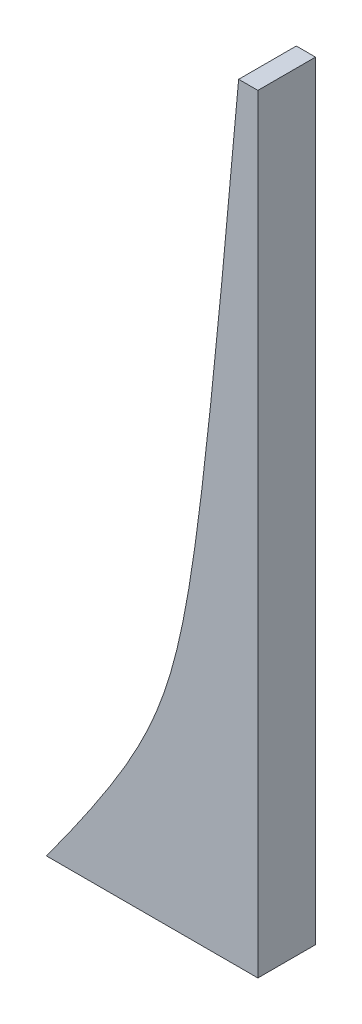
from build123d import *

# Parameters (mm, degrees)
BOSS_EXTRUDE1_DEPTH = 3


with BuildPart() as part:
    # Sketch1 → Boss-Extrude1 (new body)
    with BuildSketch(Plane.XY):
        with BuildLine():
            Line((0, 0), (11, 0))
            Line((11, 0), (11, 40))
            Line((11, 40), (10, 40))
            add(Edge.make_bspline(
                [(10, 40), (7.339858089, 10.096384463), (0, 0)],
                knots=[0, 0, 0, 1, 1, 1], degree=2, weights=[1, 3, 1]))
        make_face()
    extrude(amount=BOSS_EXTRUDE1_DEPTH)


solid = part.part
